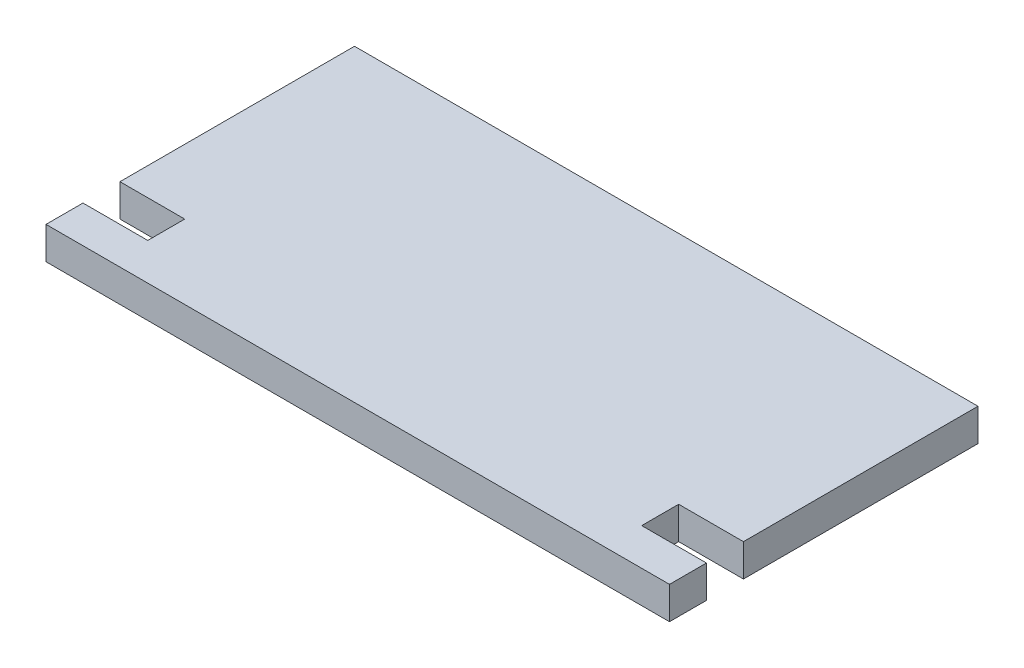
from build123d import *

# Parameters (mm, degrees)
BOSS_EXTRUDE1_DEPTH = 1.2


with BuildPart() as part:
    # Sketch1 → Boss-Extrude1 (new body)
    with BuildSketch(Plane(origin=(0, 0, 0), x_dir=(1, 0, 0), z_dir=(0, 1, 0))):
        Polygon((11.55, 5.715), (-11.55, 5.715), (-11.55, -2.975), (-9.15, -2.975), (-9.15, -4.345), (-11.55, -4.345), (-11.55, -5.715), (11.55, -5.715), (11.55, -4.345), (9.15, -4.345), (9.15, -2.975), (11.55, -2.975), align=None)
    extrude(amount=BOSS_EXTRUDE1_DEPTH)


solid = part.part
